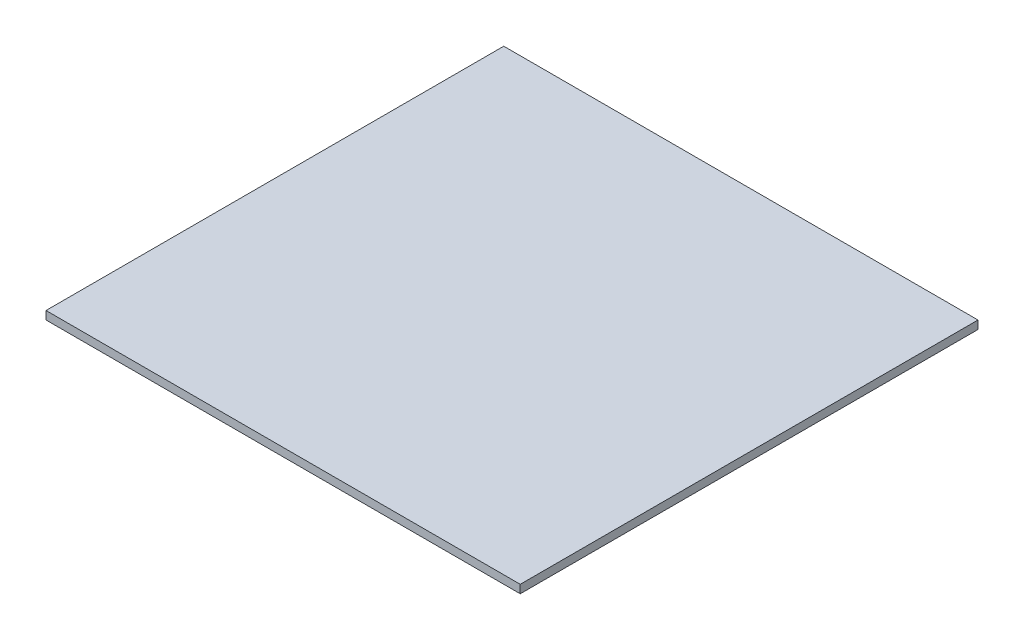
from build123d import *

# Parameters (mm, degrees)
SKETCH_1_W      = 103.6
SKETCH_1_H      = 100
EXTRUDE_1_DEPTH = 1.8


with BuildPart() as part:
    # 草图1 → 凸台-拉伸1 (new body)
    with BuildSketch(Plane(origin=(0, 0, 0), x_dir=(1, 0, 0), z_dir=(0, 1, 0))):
        with Locations((51.8, 50)):
            Rectangle(SKETCH_1_W, SKETCH_1_H)
    extrude(amount=EXTRUDE_1_DEPTH)


solid = part.part
